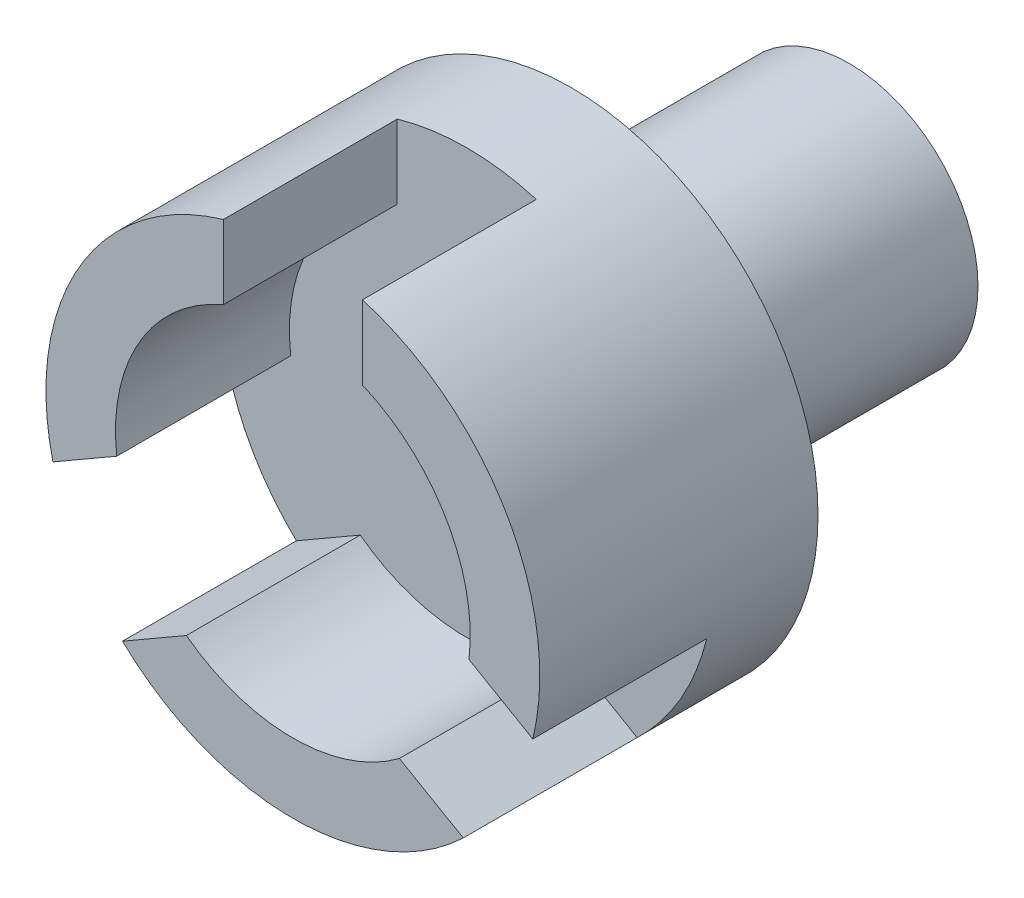
from build123d import *

# Parameters (mm, degrees)
SKETCH_1_R          = 7.1
EXTRUDE_1_DEPTH     = 8
SKETCH_2_R          = 1.7
CUT_EXTRUDE_1_DEPTH = 6
SKETCH_3_R          = 5.1
CUT_EXTRUDE_2_DEPTH = 5
SKETCH_4_R          = 3.7
SKETCH_4_R_2        = 1.7
EXTRUDE_2_DEPTH     = 8
CUT_EXTRUDE_4_DEPTH = 5


with BuildPart() as part:
    # 草图1 → 凸台-拉伸1 (new body)
    with BuildSketch(Plane.XY):
        with Locations((-2.763223282, 3.564558034)):
            Circle(SKETCH_1_R)
    extrude(amount=EXTRUDE_1_DEPTH)

    # 草图2 → 切除-拉伸1 (cut)
    with BuildSketch(Plane(origin=(0, 0, 0), x_dir=(-1, 0, 0), z_dir=(0, 0, -1))):
        with Locations((2.763223282, 3.564558034)):
            Circle(SKETCH_2_R)
    extrude(amount=-CUT_EXTRUDE_1_DEPTH, mode=Mode.SUBTRACT)

    # 草图3 → 切除-拉伸2 (cut)
    with BuildSketch(Plane.XY.offset(8)):
        with Locations((-2.763223282, 3.564558034)):
            Circle(SKETCH_3_R)
    extrude(amount=-CUT_EXTRUDE_2_DEPTH, mode=Mode.SUBTRACT)

    # 草图4 → 凸台-拉伸2 (add)
    with BuildSketch(Plane(origin=(0, 0, 0), x_dir=(-1, 0, 0), z_dir=(0, 0, -1))):
        with Locations((2.763223282, 3.564558034)):
            Circle(SKETCH_4_R)
        with Locations((2.763223282, 3.564558034)):
            Circle(SKETCH_4_R_2, mode=Mode.SUBTRACT)
    extrude(amount=EXTRUDE_2_DEPTH)

    # 草图5 → 切除-拉伸4 (cut)
    with BuildSketch(Plane.XY.offset(8)):
        with BuildLine():
            Line((-0.763223282, 4.719258572), (-0.763223282, 10.377046566))
            ThreePointArc((-0.763223282, 10.377046566), (-2.763223282, 10.664558034), (-4.763223282, 10.377046566))
            Line((-4.763223282, 10.377046566), (-4.763223282, 4.719258572))
            Line((-4.763223282, 4.719258572), (-9.663011414, 1.890364575))
            ThreePointArc((-9.663011414, 1.890364575), (-8.912003649, 0.014558034), (-7.663011414, -1.57373704))
            Line((-7.663011414, -1.57373704), (-2.763223282, 1.255156957))
            Line((-2.763223282, 1.255156957), (2.13656485, -1.57373704))
            ThreePointArc((2.13656485, -1.57373704), (3.385557085, 0.014558034), (4.13656485, 1.890364575))
            Line((4.13656485, 1.890364575), (-0.763223282, 4.719258572))
        make_face()
    extrude(amount=-CUT_EXTRUDE_4_DEPTH, mode=Mode.SUBTRACT)


solid = part.part
